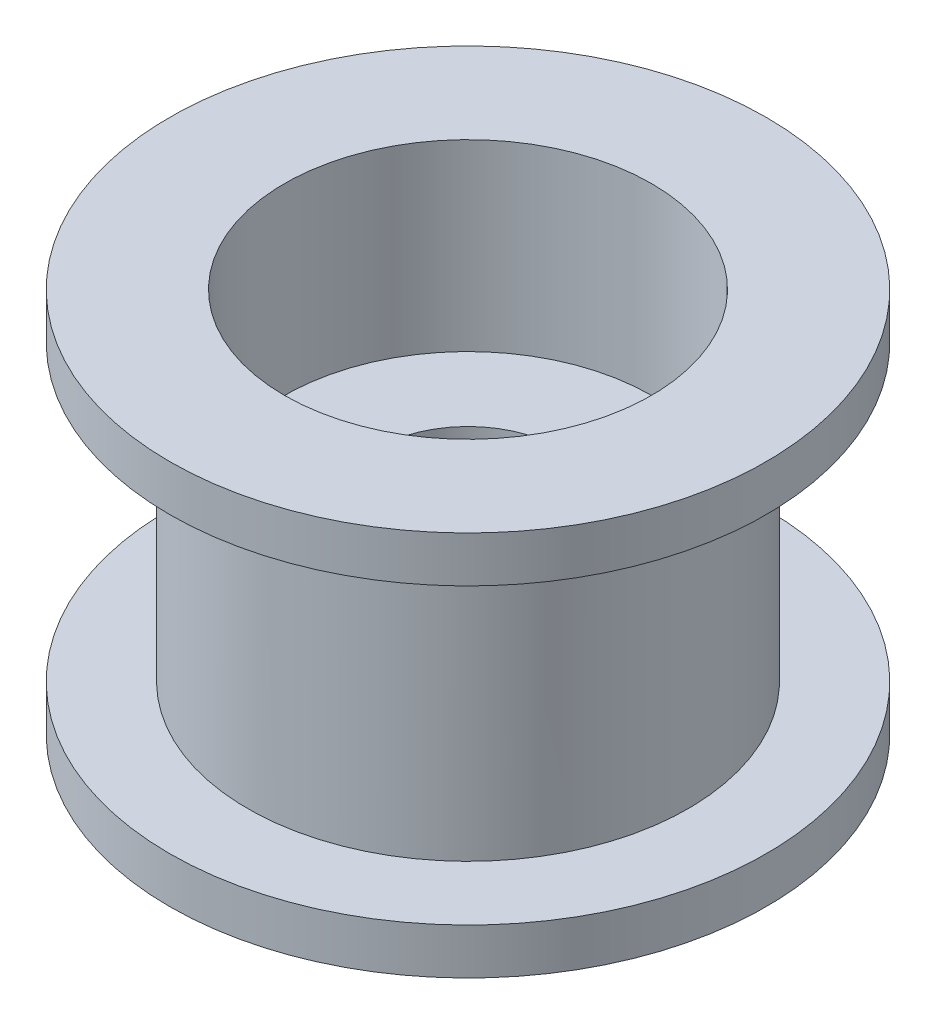
from build123d import *

# Parameters (mm, degrees)
BASES_R        = 4.8
BASE_DEPTH     = 3.2
FLANGES_R      = 6.5
FLANGE_DEPTH   = 1
TOPBORES_R     = 4
TOPBORE_DEPTH  = 4
THRUHOLES_R    = 2
THRUHOLE_DEPTH = 5.4


with BuildPart() as part:
    # BaseS → Base (new body, symmetric)
    with BuildSketch(Plane(origin=(0, 0, 0), x_dir=(1, 0, 0), z_dir=(0, 1, 0))):
        Circle(BASES_R)
    extrude(amount=BASE_DEPTH, both=True)

    # FlangeS → Flange (add)
    with BuildSketch(Plane(origin=(0, 3.2, 0), x_dir=(1, 0, 0), z_dir=(0, 1, 0))):
        Circle(FLANGES_R)
    flange = extrude(amount=FLANGE_DEPTH)

    # TopBoreS → TopBore (cut)
    with BuildSketch(Plane(origin=(0, 4.2, 0), x_dir=(1, 0, 0), z_dir=(0, 1, 0))):
        Circle(TOPBORES_R)
    topbore = extrude(amount=-TOPBORE_DEPTH, mode=Mode.SUBTRACT)

    # BoreVM: Flange, TopBore across plane
    add(flange.mirror(Plane.ZX))
    add(topbore.mirror(Plane.ZX), mode=Mode.SUBTRACT)

    # ThruHoleS → ThruHole (cut, through all)
    with BuildSketch(Plane(origin=(0, 0.2, 0), x_dir=(1, 0, 0), z_dir=(0, 1, 0))):
        Circle(THRUHOLES_R)
    extrude(amount=-THRUHOLE_DEPTH, mode=Mode.SUBTRACT)


solid = part.part
